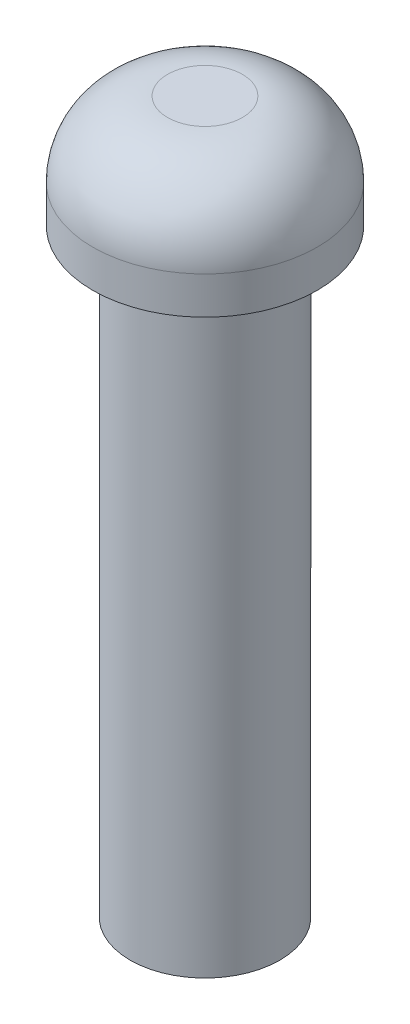
from build123d import *

# Parameters (mm, degrees)
ESQUISSE1_R        = 15
BOSS_EXTRU_1_DEPTH = 15
CONG_1_R           = 10
ESQUISSE3_R        = 10
BOSS_EXTRU_2_DEPTH = 80


with BuildPart() as part:
    # Esquisse1 → Boss.-Extru.1 (new body)
    with BuildSketch(Plane(origin=(0, 0, 0), x_dir=(1, 0, 0), z_dir=(0, 1, 0))):
        Circle(ESQUISSE1_R)
    extrude(amount=BOSS_EXTRU_1_DEPTH)

    # Congé1
    cong_1_edges = [part.edges().sort_by_distance(p)[0] for p in [
        (-15, 15, 0),
    ]]
    fillet(cong_1_edges, radius=CONG_1_R)

    # Esquisse3 → Boss.-Extru.2 (add)
    with BuildSketch(Plane.XZ):
        Circle(ESQUISSE3_R)
    extrude(amount=BOSS_EXTRU_2_DEPTH)


solid = part.part
